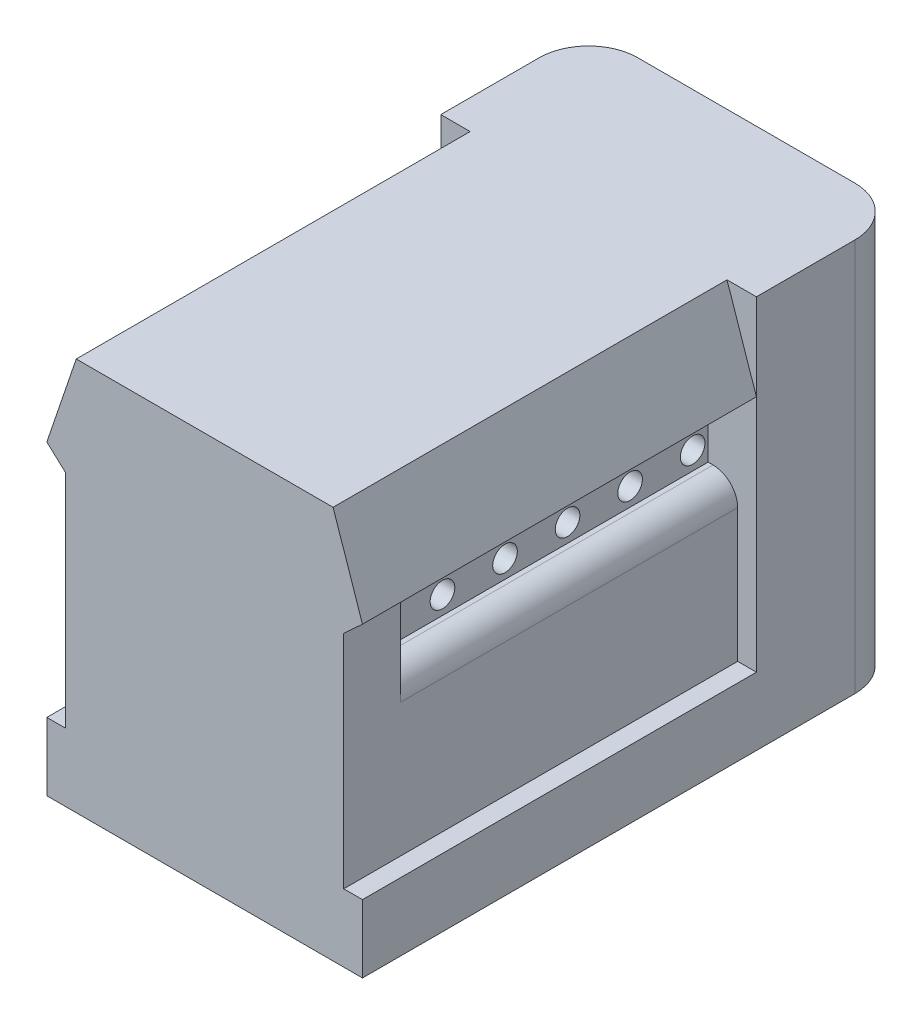
from build123d import *

# Parameters (mm, degrees)
EXTRUSION1_DEPTH           = 16
BOSS_EXTRU_1_DEPTH         = 15.960886
ESQUISSE3_R                = 0.5
ENL_V_MAT_EXTRU_1_DEPTH    = 10.0986
R_P_TITION_LIN_AIRE1_COUNT = 5
R_P_TITION_LIN_AIRE1_PITCH = 2.54
ESQUISSE4_W                = 10.409192402
ESQUISSE4_H                = 2.3
BOSS_EXTRU_2_DEPTH         = 13
ESQUISSE7_W                = 11.29860034
ESQUISSE7_H                = 2.3
BOSS_EXTRU_3_DEPTH         = 13
ESQUISSE8_R                = 0.4
BOSS_EXTRU_4_DEPTH         = 3


with BuildPart() as part:
    # Esquisse1 → Extrusion1 (new body)
    with BuildSketch(Plane.XY):
        with BuildLine():
            Line((-4.44930017, 10.640971337), (-4.44930017, 9.16466185))
            Line((-4.44930017, 9.16466185), (-4.64930017, 9.16466185))
            ThreePointArc((-4.64930017, 9.16466185), (-5.356406952, 8.871768631), (-5.64930017, 8.16466185))
            Line((-5.64930017, 8.16466185), (-5.64930017, 2.756606014))
            Line((-5.64930017, 2.756606014), (-6.41, 2.756606014))
            Line((-6.41, 2.756606014), (-6.41, 0))
            Line((-6.41, 0), (0, 0))
            Line((0, 0), (6.41, 0))
            Line((6.41, 0), (6.41, 2.756606014))
            Line((6.41, 2.756606014), (5.64930017, 2.756606014))
            Line((5.64930017, 2.756606014), (5.64930017, 8.16466185))
            ThreePointArc((5.64930017, 8.16466185), (5.356406952, 8.871768631), (4.64930017, 9.16466185))
            Line((4.64930017, 9.16466185), (4.44930017, 9.16466185))
            Line((4.44930017, 9.16466185), (4.44930017, 10.640971337))
            Line((4.44930017, 10.640971337), (6.41, 12.444168195))
            Line((6.41, 12.444168195), (5.215643019, 15.960885973))
            Line((5.215643019, 15.960885973), (-5.215643019, 15.960885973))
            Line((-5.215643019, 15.960885973), (-6.41, 12.444168195))
            Line((-6.41, 12.444168195), (-4.44930017, 10.640971337))
        make_face()
    extrude(amount=EXTRUSION1_DEPTH)

    # Esquisse2 → Boss.-Extru.1 (add)
    with BuildSketch(Plane(origin=(0, 15.960885973, 0), x_dir=(1, 0, 0), z_dir=(0, 1, 0))):
        with BuildLine():
            Line((-6.41, 0), (6.41, 0))
            Line((6.41, 0), (6.41, 4))
            ThreePointArc((6.41, 4), (5.824213562, 5.414213562), (4.41, 6))
            Line((4.41, 6), (-4.41, 6))
            ThreePointArc((-4.41, 6), (-5.824213562, 5.414213562), (-6.41, 4))
            Line((-6.41, 4), (-6.41, 0))
        make_face()
    extrude(amount=-BOSS_EXTRU_1_DEPTH)

    # Esquisse3 → Enlèv. mat.-Extru.1 (cut)
    with BuildSketch(Plane.ZY.offset(4.44930017)):
        with Locations((0.63, 9.902816594)):
            Circle(ESQUISSE3_R)
    enl_v_mat_extru_1 = extrude(amount=-ENL_V_MAT_EXTRU_1_DEPTH, mode=Mode.SUBTRACT)

    # Répétition linéaire1: Enlèv. mat.-Extru.1 ×5
    with Locations(*[(0, 0, i * R_P_TITION_LIN_AIRE1_PITCH) for i in range(1, R_P_TITION_LIN_AIRE1_COUNT)]):
        add(enl_v_mat_extru_1, mode=Mode.SUBTRACT)

    # Esquisse4 → Boss.-Extru.2 (add)
    with BuildSketch(Plane.XZ):
        with Locations((-0.190494612, 14.85)):
            Rectangle(ESQUISSE4_W, ESQUISSE4_H)
    extrude(amount=-BOSS_EXTRU_2_DEPTH)

    # Esquisse7 → Boss.-Extru.3 (add)
    with BuildSketch(Plane.XZ):
        with Locations((0, 14.85)):
            Rectangle(ESQUISSE7_W, ESQUISSE7_H)
    extrude(amount=-BOSS_EXTRU_3_DEPTH)

    # Esquisse8 → Boss.-Extru.4 (add)
    with BuildSketch(Plane.XZ):
        with Locations(Location((-0.007642762, -4.45, 0), (0, 0, 180))):  # turned: the seam where the file's is
            Circle(ESQUISSE8_R)
        with Locations(Location((-2.547642762, -4.45, 0), (0, 0, 180))):  # turned: the seam where the file's is
            Circle(ESQUISSE8_R)
        with Locations(Location((2.547642762, -4.45, 0), (0, 0, 180))):  # turned: the seam where the file's is
            Circle(ESQUISSE8_R)
    extrude(amount=BOSS_EXTRU_4_DEPTH)


solid = part.part
